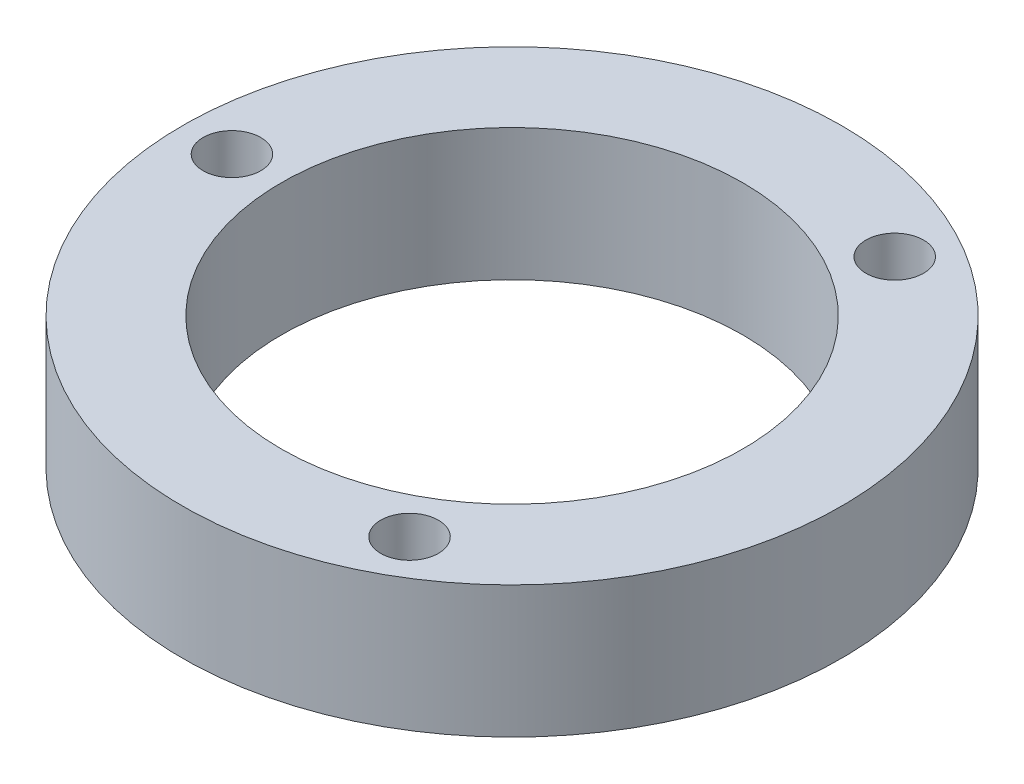
from build123d import *

# Parameters (mm, degrees)
SKETCH1_R           = 20
BOSS_EXTRUDE1_DEPTH = 8
SKETCH2_R           = 14
CUT_EXTRUDE1_DEPTH  = 8
CUT_EXTRUDE2_REACH  = 10
SKETCH3_R           = 1.75


with BuildPart() as part:
    # Sketch1 → Boss-Extrude1 (new body)
    with BuildSketch(Plane.XZ):
        with Locations((-34.143225555, 5.12970783)):
            Circle(SKETCH1_R)
    extrude(amount=BOSS_EXTRUDE1_DEPTH)

    # Sketch2 → Cut-Extrude1 (cut)
    with BuildSketch(Plane(origin=(0, 0, 0), x_dir=(1, 0, 0), z_dir=(0, 1, 0))):
        with Locations((-34.143225555, -5.12970783)):
            Circle(SKETCH2_R)
    extrude(amount=-CUT_EXTRUDE1_DEPTH, mode=Mode.SUBTRACT)

    # Sketch3 → Cut-Extrude2 (cut, up to next)
    with BuildSketch(Plane.XZ.offset(8), mode=Mode.PRIVATE) as cut_extrude2_sk1:
        with Locations((-25.643225555, 19.852139695)):
            Circle(SKETCH3_R)
    cut_extrude2_tool1 = extrude(cut_extrude2_sk1.sketch, amount=-CUT_EXTRUDE2_REACH, mode=Mode.PRIVATE) & part.part
    add(cut_extrude2_tool1.solids().sort_by_distance((-25.643226, -8, 19.85214))[0], mode=Mode.SUBTRACT)
    # Sketch3 → Cut-Extrude2 (cut, up to next)
    with BuildSketch(Plane.XZ.offset(8), mode=Mode.PRIVATE) as cut_extrude2_sk2:
        with Locations((-25.643225555, -9.592724034)):
            Circle(SKETCH3_R)
    cut_extrude2_tool2 = extrude(cut_extrude2_sk2.sketch, amount=-CUT_EXTRUDE2_REACH, mode=Mode.PRIVATE) & part.part
    add(cut_extrude2_tool2.solids().sort_by_distance((-25.643226, -8, -9.592724))[0], mode=Mode.SUBTRACT)
    # Sketch3 → Cut-Extrude2 (cut, up to next)
    with BuildSketch(Plane.XZ.offset(8), mode=Mode.PRIVATE) as cut_extrude2_sk3:
        with Locations((-51.143225555, 5.12970783)):
            Circle(SKETCH3_R)
    cut_extrude2_tool3 = extrude(cut_extrude2_sk3.sketch, amount=-CUT_EXTRUDE2_REACH, mode=Mode.PRIVATE) & part.part
    add(cut_extrude2_tool3.solids().sort_by_distance((-51.143226, -8, 5.129708))[0], mode=Mode.SUBTRACT)


solid = part.part
